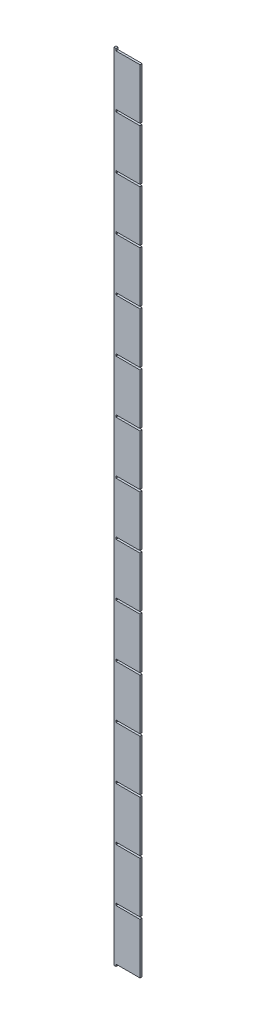
from build123d import *

# Parameters (mm, degrees)
BOSS_EXTRUDE1_DEPTH = 4


with BuildPart() as part:
    # Sketch1 → Boss-Extrude1 (new body)
    with BuildSketch(Plane.XY):
        Polygon((-9.08248368, 748), (-9.08248368, 752), (-13.08248368, 752), (-13.08248368, -752), (-9.08248368, -752), (-9.080975173, -748), (36.302257826, -748), (36.302257826, -652), (-9.08248368, -652), (-9.080975173, -648), (36.302257826, -648), (36.302257826, -552), (-9.08248368, -552), (-9.080975173, -548), (36.302257826, -548), (36.302257826, -452), (-9.08248368, -452), (-9.080975173, -448), (36.302257826, -448), (36.302257826, -352), (-9.08248368, -352), (-9.080975173, -348), (36.302257826, -348), (36.302257826, -252), (-9.08248368, -252), (-9.080975173, -248), (36.302257826, -248), (36.302257826, -152), (-9.08248368, -152), (-9.080975173, -148), (36.302257826, -148), (36.302257826, -52), (-9.08248368, -52), (-9.080975173, -48), (36.302257826, -48), (36.302257826, 48), (-9.08248368, 48), (-9.080975173, 52), (36.302257826, 52), (36.302257826, 148), (-9.08248368, 148), (-9.080975173, 152), (36.302257826, 152), (36.302257826, 248), (-9.08248368, 248), (-9.080975173, 252), (36.302257826, 252), (36.302257826, 348), (-9.08248368, 348), (-9.080975173, 352), (36.302257826, 352), (36.302257826, 448), (-9.08248368, 448), (-9.080975173, 452), (36.302257826, 452), (36.302257826, 548), (-9.08248368, 548), (-9.080975173, 552), (36.302257826, 552), (36.302257826, 648), (-9.08248368, 648), (-9.080975173, 652), (36.302257826, 652), (36.302257826, 748), align=None)
    extrude(amount=BOSS_EXTRUDE1_DEPTH)


solid = part.part
